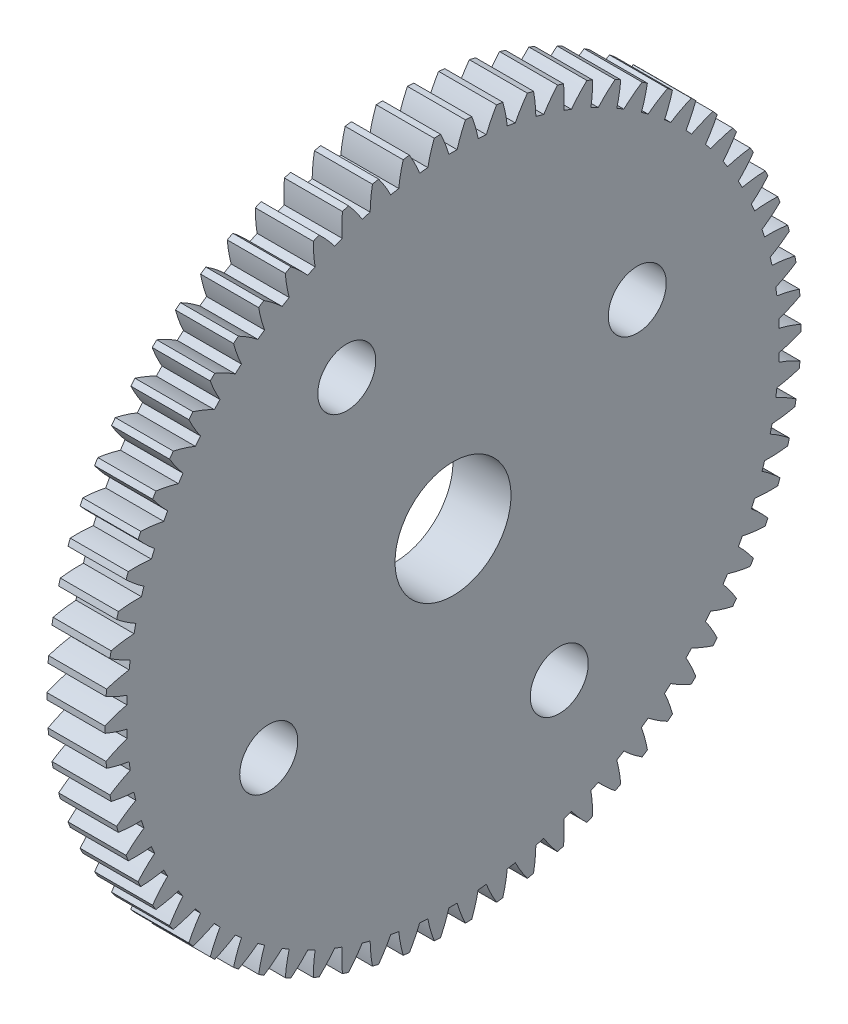
from build123d import *

# Parameters (mm, degrees)
BASPROSKE_W        = 3
BASPROSKE_H        = 18
TOOTHCUT_DEPTH     = 26.632011236
TEETHCUTS_COUNT    = 70
TEETHCUTS_ANGLE    = 354.857142857
BORSKE_R           = 3
BORE_DEPTH         = 8.0000508
SKETCH3_R          = 14.5
SKETCH3_R_2        = 7.5
CUT_EXTRUDE3_DEPTH = 0.5
SKETCH4_R          = 1.5
CUT_EXTRUDE4_DEPTH = 26.570195982


with BuildPart() as part:
    # BasProSke → Base-Revolve (revolve)
    with BuildSketch(Plane(origin=(0, 0, 0), x_dir=(1, 0, 0), z_dir=(0, 1, 0)), mode=Mode.PRIVATE) as base_revolve_sk:
        with Locations((1.5, 9)):
            Rectangle(BASPROSKE_W, BASPROSKE_H)
    revolve(base_revolve_sk.sketch.rotate(Axis((-10, 0, 0), (1, 0, 0)), 180), axis=Axis((-10, 0, 0), (1, 0, 0)))

    # TooCutSke → ToothCut (cut, through all)
    with BuildSketch(Plane(origin=(0, 0, 0), x_dir=(0, 0, -1), z_dir=(1, 0, 0))):
        with BuildLine():
            ThreePointArc((0.21220331, 16.872665639), (0, 16.874), (-0.21220331, 16.872665639))
            ThreePointArc((-0.21220331, 16.872665639), (-0.409386856, 17.452785162), (-0.656544674, 18.013439268))
            ThreePointArc((-0.656544674, 18.013439268), (0, 18.0254), (0.656544674, 18.013439268))
            ThreePointArc((0.656544674, 18.013439268), (0.409386856, 17.452785162), (0.21220331, 16.872665639))
        make_face()
    toothcut = extrude(amount=TOOTHCUT_DEPTH, mode=Mode.SUBTRACT)

    # TeethCuts: ToothCut ×70 about axis
    teethcuts_axis = Axis((-10, 0, 0), (1, 0, 0))
    for i in range(1, TEETHCUTS_COUNT):
        add(toothcut.rotate(teethcuts_axis, i * TEETHCUTS_ANGLE / (TEETHCUTS_COUNT - 1)), mode=Mode.SUBTRACT)

    # BorSke → Bore (cut, symmetric)
    with BuildSketch(Plane(origin=(0, 0, 0), x_dir=(0, 0, -1), z_dir=(1, 0, 0))):
        with Locations(Location((0, 0, 0), (0, 0, 180))):
            Circle(BORSKE_R)
    extrude(amount=BORE_DEPTH, both=True, mode=Mode.SUBTRACT)

    # Sketch3 → Cut-Extrude3 (cut)
    with BuildSketch(Plane.ZY):
        Circle(SKETCH3_R)
        Circle(SKETCH3_R_2, mode=Mode.SUBTRACT)
    extrude(amount=-CUT_EXTRUDE3_DEPTH, mode=Mode.SUBTRACT)

    # Sketch4 → Cut-Extrude4 (cut, through all)
    with BuildSketch(Plane.ZY.offset(-0.5)):
        with Locations((5.494804111, 9.529277401)):
            Circle(SKETCH4_R)
        with Locations((9.529277401, -5.494804111)):
            Circle(SKETCH4_R)
        with Locations((-5.494804111, -9.529277401)):
            Circle(SKETCH4_R)
        with Locations((-9.529277401, 5.494804111)):
            Circle(SKETCH4_R)
    extrude(amount=-CUT_EXTRUDE4_DEPTH, mode=Mode.SUBTRACT)


solid = part.part
